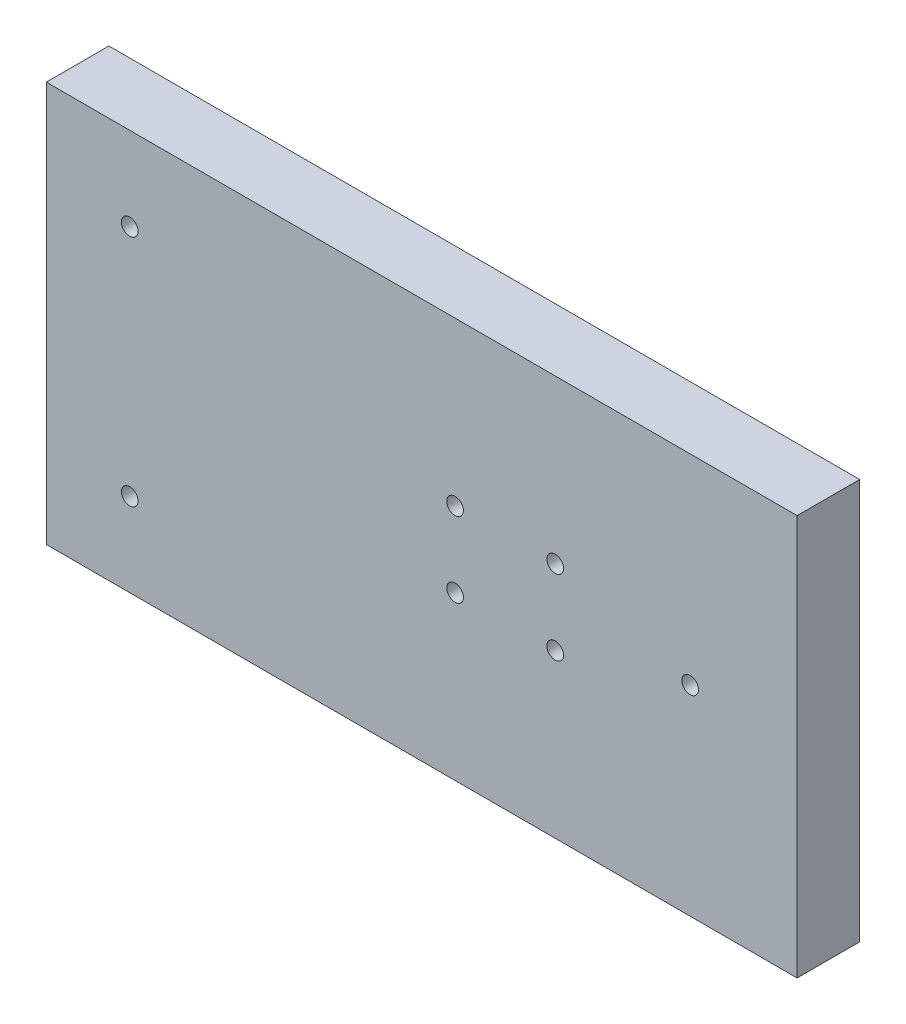
from build123d import *

# Parameters (mm, degrees)
SKETCH1_W           = 180
SKETCH1_H           = 96
SKETCH1_R           = 2
BOSS_EXTRUDE1_DEPTH = 15


with BuildPart() as part:
    # Sketch1 → Boss-Extrude1 (new body)
    with BuildSketch(Plane.XY):
        with Locations((-615.534520475, 268.509389187)):
            Rectangle(SKETCH1_W, SKETCH1_H)
        with Locations((-583.534520475, 277.509389187)):
            Circle(SKETCH1_R, mode=Mode.SUBTRACT)
        with Locations((-607.534520475, 277.509389187)):
            Circle(SKETCH1_R, mode=Mode.SUBTRACT)
        with Locations((-583.534520475, 259.509389187)):
            Circle(SKETCH1_R, mode=Mode.SUBTRACT)
        with Locations((-607.534520475, 259.509389187)):
            Circle(SKETCH1_R, mode=Mode.SUBTRACT)
        with Locations((-685.534520475, 296.509389187)):
            Circle(SKETCH1_R, mode=Mode.SUBTRACT)
        with Locations((-685.534520475, 240.509389187)):
            Circle(SKETCH1_R, mode=Mode.SUBTRACT)
        with Locations((-551.183631115, 268.509389187)):
            Circle(SKETCH1_R, mode=Mode.SUBTRACT)
    extrude(amount=BOSS_EXTRUDE1_DEPTH)


solid = part.part
